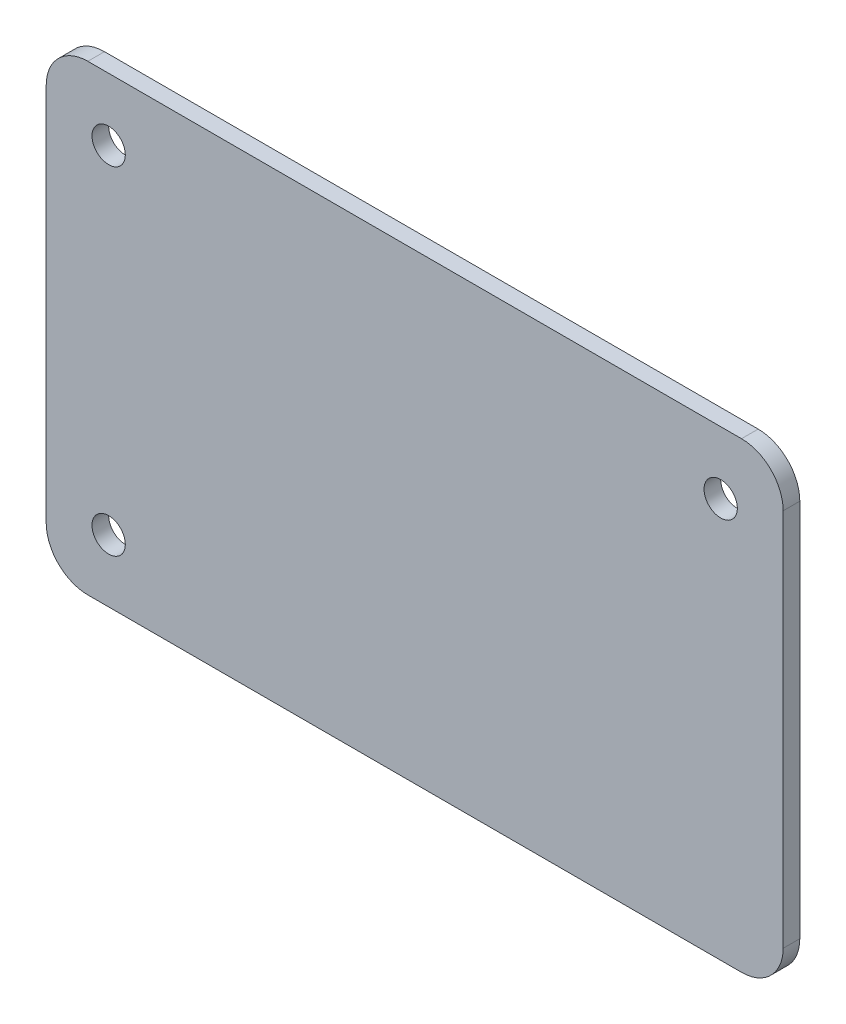
from build123d import *

# Parameters (mm, degrees)
ESQUISSE1_R        = 4
BOSS_EXTRU_1_DEPTH = 4


with BuildPart() as part:
    # Esquisse1 → Boss.-Extru.1 (new body)
    with BuildSketch(Plane.XY):
        with BuildLine():
            Line((78.5, -55.5), (-78.5, -55.5))
            ThreePointArc((-78.5, -55.5), (-85.571067812, -52.571067812), (-88.5, -45.5))
            Line((-88.5, -45.5), (-88.5, 45.5))
            ThreePointArc((-88.5, 45.5), (-85.571067812, 52.571067812), (-78.5, 55.5))
            Line((-78.5, 55.5), (78.5, 55.5))
            ThreePointArc((78.5, 55.5), (85.571067812, 52.571067812), (88.5, 45.5))
            Line((88.5, 45.5), (88.5, -45.5))
            ThreePointArc((88.5, -45.5), (85.571067812, -52.571067812), (78.5, -55.5))
        make_face()
        with Locations((-73.5, 40.5)):
            Circle(ESQUISSE1_R, mode=Mode.SUBTRACT)
        with Locations((73.5, 40.5)):
            Circle(ESQUISSE1_R, mode=Mode.SUBTRACT)
        with Locations((-73.5, -40.5)):
            Circle(ESQUISSE1_R, mode=Mode.SUBTRACT)
    extrude(amount=BOSS_EXTRU_1_DEPTH)


solid = part.part
